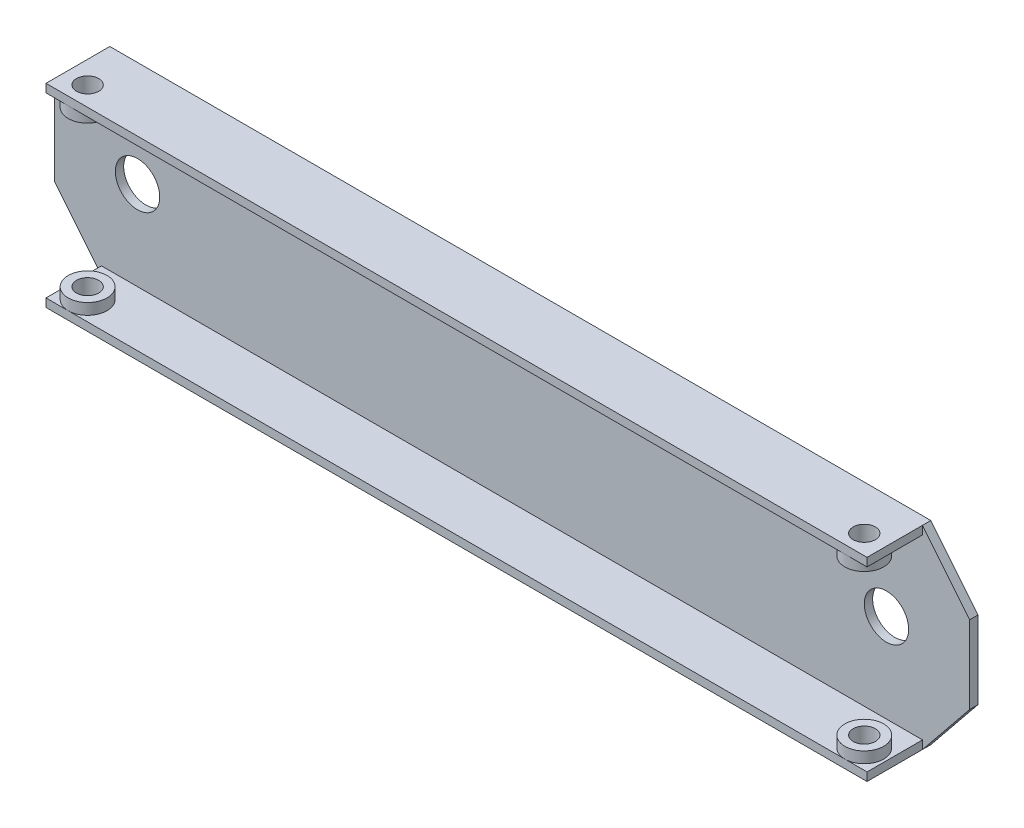
from build123d import *

# Parameters (mm, degrees)
SALIENTE_EXTRUIR1_DEPTH = 1.5
CROQUIS4_W              = 148
CROQUIS4_H              = 1.5
SALIENTE_EXTRUIR2_DEPTH = 10
CROQUIS5_W              = 148
CROQUIS5_H              = 1.5
SALIENTE_EXTRUIR3_DEPTH = 10
CROQUIS6_R              = 2
CORTAR_EXTRUIR6_DEPTH   = 3.5
CROQUIS9_R              = 3.5
SALIENTE_EXTRUIR5_DEPTH = 2
CROQUIS11_R             = 2
CORTAR_EXTRUIR7_DEPTH   = 2
CROQUIS12_R             = 3.5
SALIENTE_EXTRUIR6_DEPTH = 2
CROQUIS13_R             = 2
CORTAR_EXTRUIR8_DEPTH   = 2
CORTAR_EXTRUIR9_REACH   = 37
CROQUIS14_R             = 2
CROQUIS15_R             = 3.5
SALIENTE_EXTRUIR7_DEPTH = 2
CROQUIS16_R             = 2
CORTAR_EXTRUIR10_DEPTH  = 2
CORTAR_EXTRUIR11_REACH  = 37
CROQUIS17_R             = 2
CROQUIS18_R             = 3.5
SALIENTE_EXTRUIR8_DEPTH = 2
CROQUIS19_R             = 2
CORTAR_EXTRUIR12_DEPTH  = 2
CORTAR_EXTRUIR13_REACH  = 3.5
CROQUIS20_R             = 4


with BuildPart() as part:
    # Croquis1 → Saliente-Extruir1 (new body)
    with BuildSketch(Plane.XY):
        Polygon((110.114969998, 26.806936713), (118.614969998, 16.306936713), (118.614969998, 2.306936713), (110.114969998, -8.193063287), (-37.885030002, -8.193063287), (-46.385030002, 2.306936713), (-46.385030002, 16.306936713), (-37.885030002, 26.806936713), align=None)
    extrude(amount=SALIENTE_EXTRUIR1_DEPTH)

    # Croquis4 → Saliente-Extruir2 (add)
    with BuildSketch(Plane.XY.offset(1.5)):
        with Locations((36.114969998, 26.056936713)):
            Rectangle(CROQUIS4_W, CROQUIS4_H)
    extrude(amount=SALIENTE_EXTRUIR2_DEPTH)

    # Croquis5 → Saliente-Extruir3 (add)
    with BuildSketch(Plane.XY.offset(1.5)):
        with Locations((36.114969998, -7.443063287)):
            Rectangle(CROQUIS5_W, CROQUIS5_H)
    extrude(amount=SALIENTE_EXTRUIR3_DEPTH)

    # Croquis6 → Cortar-Extruir6 (cut)
    with BuildSketch(Plane(origin=(0, 26.806936713, 0), x_dir=(1, 0, 0), z_dir=(0, 1, 0))):
        with Locations((106.114969998, -8)):
            Circle(CROQUIS6_R)
        with Locations((-33.885030002, -8)):
            Circle(CROQUIS6_R)
    extrude(amount=-CORTAR_EXTRUIR6_DEPTH, mode=Mode.SUBTRACT)

    # Croquis9 → Saliente-Extruir5 (add)
    with BuildSketch(Plane.XZ.offset(-25.306936713)):
        with Locations((-33.885030002, 8)):
            Circle(CROQUIS9_R)
    extrude(amount=SALIENTE_EXTRUIR5_DEPTH)

    # Croquis11 → Cortar-Extruir7 (cut)
    with BuildSketch(Plane.XZ.offset(-23.306936713)):
        with Locations((-33.885030002, 8)):
            Circle(CROQUIS11_R)
    extrude(amount=-CORTAR_EXTRUIR7_DEPTH, mode=Mode.SUBTRACT)

    # Croquis12 → Saliente-Extruir6 (add)
    with BuildSketch(Plane.XZ.offset(-25.306936713)):
        with Locations((106.114969998, 8)):
            Circle(CROQUIS12_R)
    extrude(amount=SALIENTE_EXTRUIR6_DEPTH)

    # Croquis13 → Cortar-Extruir8 (cut)
    with BuildSketch(Plane.XZ.offset(-23.306936713)):
        with Locations((106.114969998, 8)):
            Circle(CROQUIS13_R)
    extrude(amount=-CORTAR_EXTRUIR8_DEPTH, mode=Mode.SUBTRACT)

    # Croquis14 → Cortar-Extruir9 (cut, up to next)
    with BuildSketch(Plane.XZ.offset(8.193063287), mode=Mode.PRIVATE) as cortar_extruir9_sk1:
        with Locations((-33.885030002, 8)):
            Circle(CROQUIS14_R)
    cortar_extruir9_tool1 = extrude(cortar_extruir9_sk1.sketch, amount=-CORTAR_EXTRUIR9_REACH, mode=Mode.PRIVATE) & part.part
    add(cortar_extruir9_tool1.solids().sort_by_distance((-33.88503, -8.193063, 8))[0], mode=Mode.SUBTRACT)

    # Croquis15 → Saliente-Extruir7 (add)
    with BuildSketch(Plane(origin=(0, -6.693063287, 0), x_dir=(1, 0, 0), z_dir=(0, 1, 0))):
        with Locations((-33.885030002, -8)):
            Circle(CROQUIS15_R)
    extrude(amount=SALIENTE_EXTRUIR7_DEPTH)

    # Croquis16 → Cortar-Extruir10 (cut)
    with BuildSketch(Plane(origin=(0, -4.693063287, 0), x_dir=(1, 0, 0), z_dir=(0, 1, 0))):
        with Locations((-33.885030002, -8)):
            Circle(CROQUIS16_R)
    extrude(amount=-CORTAR_EXTRUIR10_DEPTH, mode=Mode.SUBTRACT)

    # Croquis17 → Cortar-Extruir11 (cut, up to next)
    with BuildSketch(Plane.XZ.offset(8.193063287), mode=Mode.PRIVATE) as cortar_extruir11_sk1:
        with Locations((106.114969998, 8)):
            Circle(CROQUIS17_R)
    cortar_extruir11_tool1 = extrude(cortar_extruir11_sk1.sketch, amount=-CORTAR_EXTRUIR11_REACH, mode=Mode.PRIVATE) & part.part
    add(cortar_extruir11_tool1.solids().sort_by_distance((106.11497, -8.193063, 8))[0], mode=Mode.SUBTRACT)

    # Croquis18 → Saliente-Extruir8 (add)
    with BuildSketch(Plane(origin=(0, -6.693063287, 0), x_dir=(1, 0, 0), z_dir=(0, 1, 0))):
        with Locations((106.114969998, -8)):
            Circle(CROQUIS18_R)
    extrude(amount=SALIENTE_EXTRUIR8_DEPTH)

    # Croquis19 → Cortar-Extruir12 (cut)
    with BuildSketch(Plane(origin=(0, -4.693063287, 0), x_dir=(1, 0, 0), z_dir=(0, 1, 0))):
        with Locations((106.114969998, -8)):
            Circle(CROQUIS19_R)
    extrude(amount=-CORTAR_EXTRUIR12_DEPTH, mode=Mode.SUBTRACT)

    # Croquis20 → Cortar-Extruir13 (cut, up to next)
    with BuildSketch(Plane.XY.offset(1.5), mode=Mode.PRIVATE) as cortar_extruir13_sk1:
        with Locations((-31.385030002, 9.306936713)):
            Circle(CROQUIS20_R)
    cortar_extruir13_tool1 = extrude(cortar_extruir13_sk1.sketch, amount=-CORTAR_EXTRUIR13_REACH, mode=Mode.PRIVATE) & part.part
    add(cortar_extruir13_tool1.solids().sort_by_distance((-31.38503, 9.306937, 1.5))[0], mode=Mode.SUBTRACT)
    # Croquis20 → Cortar-Extruir13 (cut, up to next)
    with BuildSketch(Plane.XY.offset(1.5), mode=Mode.PRIVATE) as cortar_extruir13_sk2:
        with Locations((103.614969998, 9.306936713)):
            Circle(CROQUIS20_R)
    cortar_extruir13_tool2 = extrude(cortar_extruir13_sk2.sketch, amount=-CORTAR_EXTRUIR13_REACH, mode=Mode.PRIVATE) & part.part
    add(cortar_extruir13_tool2.solids().sort_by_distance((103.61497, 9.306937, 1.5))[0], mode=Mode.SUBTRACT)


solid = part.part
